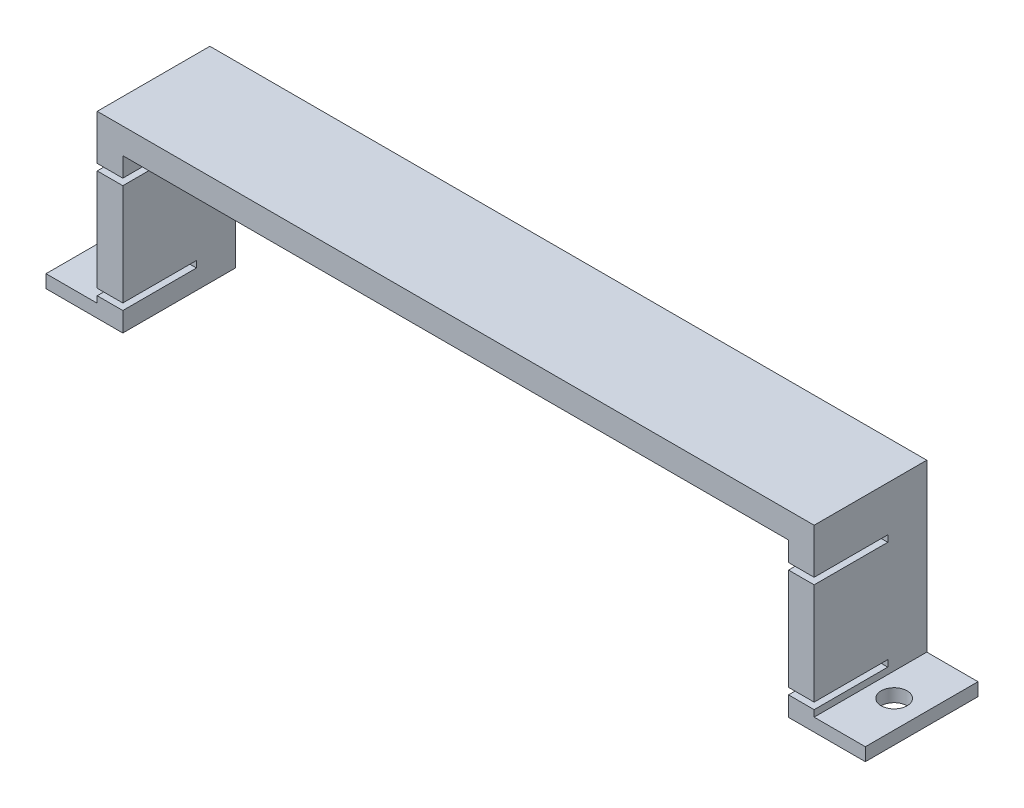
from build123d import *

# Parameters (mm, degrees)
SKETCH1_W           = 160
SKETCH1_H           = 22
BOSS_EXTRUDE1_DEPTH = 35
SKETCH4_W           = 130
SKETCH4_H           = 30
CUT_EXTRUDE3_DEPTH  = 23
SKETCH5_W           = 10
SKETCH5_H           = 32.46
CUT_EXTRUDE4_DEPTH  = 23
SKETCH7_W           = 14.38
SKETCH7_H           = 1.27
CUT_EXTRUDE5_DEPTH  = 151
SKETCH8_R           = 2.54
CUT_EXTRUDE6_DEPTH  = 3.54


with BuildPart() as part:
    # Sketch1 → Boss-Extrude1 (new body)
    with BuildSketch(Plane(origin=(0, 0, 0), x_dir=(1, 0, 0), z_dir=(0, 1, 0))):
        with Locations((80, 11)):
            Rectangle(SKETCH1_W, SKETCH1_H)
    extrude(amount=BOSS_EXTRUDE1_DEPTH)

    # Sketch4 → Cut-Extrude3 (cut, through all)
    with BuildSketch(Plane.XY):
        with Locations((80, 15)):
            Rectangle(SKETCH4_W, SKETCH4_H)
    extrude(amount=-CUT_EXTRUDE3_DEPTH, mode=Mode.SUBTRACT)

    # Sketch5 → Cut-Extrude4 (cut, through all)
    with BuildSketch(Plane.XY):
        with Locations((5, 18.77)):
            Rectangle(SKETCH5_W, SKETCH5_H)
        with Locations((155, 18.77)):
            Rectangle(SKETCH5_W, SKETCH5_H)
    extrude(amount=-CUT_EXTRUDE4_DEPTH, mode=Mode.SUBTRACT)

    # Sketch7 → Cut-Extrude5 (cut, through all)
    with BuildSketch(Plane.ZY.offset(-10)):
        with Locations((-7.19, 4.445)):
            Rectangle(SKETCH7_W, SKETCH7_H)
        with Locations((-7.19, 25.555)):
            Rectangle(SKETCH7_W, SKETCH7_H)
    extrude(amount=-CUT_EXTRUDE5_DEPTH, mode=Mode.SUBTRACT)

    # Sketch8 → Cut-Extrude6 (cut, through all)
    with BuildSketch(Plane(origin=(0, 2.54, 0), x_dir=(1, 0, 0), z_dir=(0, 1, 0))):
        with Locations((154.621372276, 11)):
            Circle(SKETCH8_R)
        with Locations((5, 11)):
            Circle(SKETCH8_R)
    extrude(amount=-CUT_EXTRUDE6_DEPTH, mode=Mode.SUBTRACT)


solid = part.part
